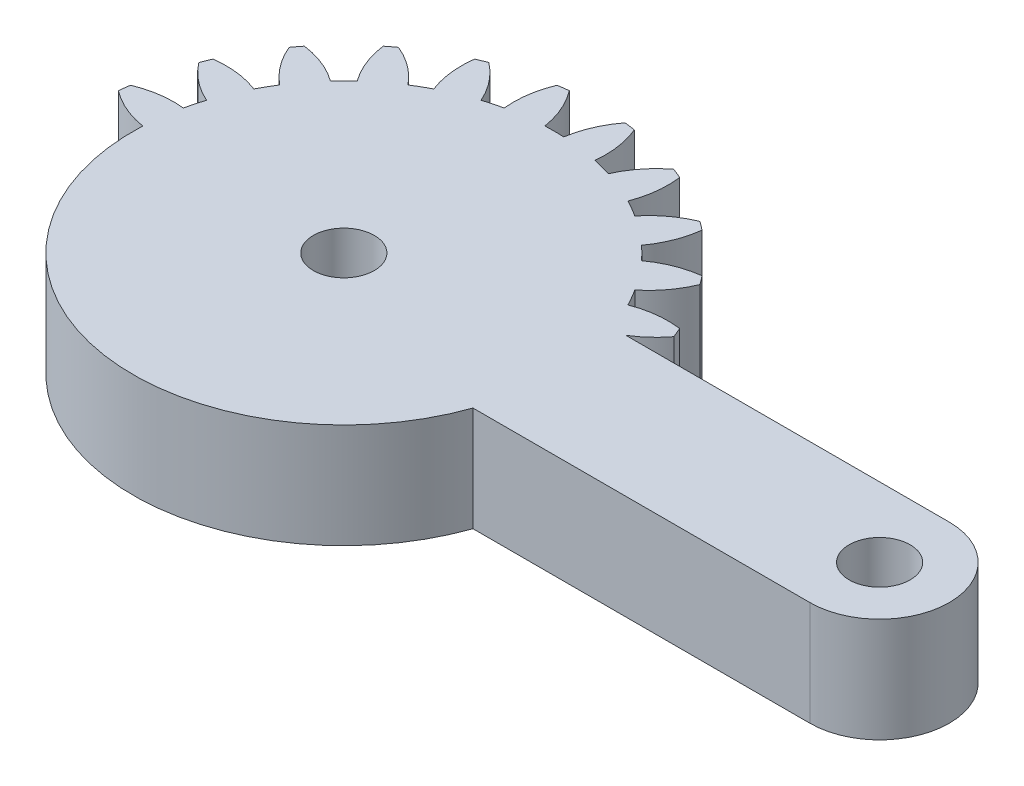
from build123d import *
from build123d.topology import SkipClean

# Parameters (mm, degrees)
SKETCH1_R           = 1.75
BOSS_EXTRUDE1_DEPTH = 4
CUT_EXTRUDE1_DEPTH  = 10
MOVE_FACE1_BY       = 2


with BuildPart() as part:
    # Sketch1 → Boss-Extrude1 (new body)
    with BuildSketch(Plane(origin=(0, 0, 0), x_dir=(1, 0, 0), z_dir=(0, 1, 0))):
        with BuildLine():
            Line((20.643657446, 4), (2.081641936, 4))
            ThreePointArc((2.081641936, 4), (2.861028333, 4.588201733), (3.521749436, 5.30713988))
            ThreePointArc((3.521749436, 5.30713988), (3.405395609, 5.596745198), (3.282888305, 5.883801663))
            ThreePointArc((3.282888305, 5.883801663), (1.93527598, 5.894040025), (0.627094961, 5.57027124))
            ThreePointArc((0.627094961, 5.57027124), (0.366286148, 6.046375), (0.084372603, 6.510293938))
            ThreePointArc((0.084372603, 6.510293938), (1.018855105, 7.48132754), (1.683794586, 8.65351323))
            ThreePointArc((1.683794586, 8.65351323), (1.496450048, 8.903135899), (1.303821399, 9.148703928))
            ThreePointArc((1.303821399, 9.148703928), (-0.000522033, 8.809805691), (-1.180330337, 8.158486898))
            ThreePointArc((-1.180330337, 8.158486898), (-1.555477026, 8.550865528), (-1.947855656, 8.926012217))
            ThreePointArc((-1.947855656, 8.926012217), (-1.296536862, 10.105820521), (-0.957638625, 11.410163953))
            ThreePointArc((-0.957638625, 11.410163953), (-1.203206655, 11.602792602), (-1.452829324, 11.79013714))
            ThreePointArc((-1.452829324, 11.79013714), (-2.625015014, 11.125197659), (-3.596048616, 10.190715157))
            ThreePointArc((-3.596048616, 10.190715157), (-4.059967554, 10.472628702), (-4.536071314, 10.733437515))
            ThreePointArc((-4.536071314, 10.733437515), (-4.212302529, 12.041618533), (-4.222540891, 13.389230859))
            ThreePointArc((-4.222540891, 13.389230859), (-4.509597355, 13.511738163), (-4.799202674, 13.62809199))
            ThreePointArc((-4.799202674, 13.62809199), (-5.759348103, 12.682425791), (-6.455432668, 11.528463019))
            ThreePointArc((-6.455432668, 11.528463019), (-6.976508546, 11.680699536), (-7.503891752, 11.809396783))
            ThreePointArc((-7.503891752, 11.809396783), (-7.529737283, 13.156800143), (-7.888414517, 14.455843809))
            ThreePointArc((-7.888414517, 14.455843809), (-8.197396993, 14.499881098), (-8.507248835, 14.537314892))
            ThreePointArc((-8.507248835, 14.537314892), (-9.18992168, 13.375367565), (-9.563620196, 12.080565177))
            ThreePointArc((-9.563620196, 12.080565177), (-10.106342554, 12.09275), (-10.649064912, 12.080565177))
            ThreePointArc((-10.649064912, 12.080565177), (-11.022763428, 13.375367565), (-11.705436272, 14.537314892))
            ThreePointArc((-11.705436272, 14.537314892), (-12.015288115, 14.499881098), (-12.324270591, 14.455843809))
            ThreePointArc((-12.324270591, 14.455843809), (-12.682947825, 13.156800143), (-12.708793355, 11.809396783))
            ThreePointArc((-12.708793355, 11.809396783), (-13.236176561, 11.680699536), (-13.757252439, 11.528463019))
            ThreePointArc((-13.757252439, 11.528463019), (-14.453337005, 12.682425791), (-15.413482434, 13.62809199))
            ThreePointArc((-15.413482434, 13.62809199), (-15.703087752, 13.511738163), (-15.990144217, 13.389230859))
            ThreePointArc((-15.990144217, 13.389230859), (-16.000382579, 12.041618533), (-15.676613793, 10.733437515))
            ThreePointArc((-15.676613793, 10.733437515), (-16.152717554, 10.472628702), (-16.616636492, 10.190715157))
            ThreePointArc((-16.616636492, 10.190715157), (-17.587670094, 11.125197659), (-18.759855783, 11.79013714))
            ThreePointArc((-18.759855783, 11.79013714), (-19.009478453, 11.602792602), (-19.255046482, 11.410163953))
            ThreePointArc((-19.255046482, 11.410163953), (-18.916148245, 10.105820521), (-18.264829452, 8.926012217))
            ThreePointArc((-18.264829452, 8.926012217), (-18.657208082, 8.550865528), (-19.032354771, 8.158486898))
            ThreePointArc((-19.032354771, 8.158486898), (-20.212163074, 8.809805691), (-21.516506507, 9.148703928))
            ThreePointArc((-21.516506507, 9.148703928), (-21.709135156, 8.903135899), (-21.896479694, 8.65351323))
            ThreePointArc((-21.896479694, 8.65351323), (-21.231540213, 7.48132754), (-20.297057711, 6.510293938))
            ThreePointArc((-20.297057711, 6.510293938), (-20.578971255, 6.046375), (-20.839780068, 5.57027124))
            ThreePointArc((-20.839780068, 5.57027124), (-22.147961087, 5.894040025), (-23.495573413, 5.883801663))
            ThreePointArc((-23.495573413, 5.883801663), (-23.618080717, 5.596745198), (-23.734434544, 5.30713988))
            ThreePointArc((-23.734434544, 5.30713988), (-22.788768345, 4.346994451), (-21.634805572, 3.650909885))
            ThreePointArc((-21.634805572, 3.650909885), (-21.78704209, 3.129834008), (-21.915739337, 2.602450802))
            ThreePointArc((-21.915739337, 2.602450802), (-23.263142697, 2.576605271), (-24.562186363, 2.217928037))
            ThreePointArc((-24.562186363, 2.217928037), (-24.606223651, 1.908945561), (-24.643657446, 1.599093719))
            ThreePointArc((-24.643657446, 1.599093719), (-23.481710119, 0.916420874), (-22.186907731, 0.542722358))
            ThreePointArc((-22.186907731, 0.542722358), (-22.199092554, 0), (-22.186907731, -0.542722358))
            ThreePointArc((-22.186907731, -0.542722358), (-23.481710119, -0.916420874), (-24.643657446, -1.599093719))
            ThreePointArc((-24.643657446, -1.599093719), (-24.606223651, -1.908945561), (-24.562186363, -2.217928037))
            ThreePointArc((-24.562186363, -2.217928037), (-23.263142697, -2.576605271), (-21.915739337, -2.602450802))
            ThreePointArc((-21.915739337, -2.602450802), (-21.78704209, -3.129834008), (-21.634805572, -3.650909885))
            ThreePointArc((-21.634805572, -3.650909885), (-22.788768345, -4.346994451), (-23.734434544, -5.30713988))
            ThreePointArc((-23.734434544, -5.30713988), (-23.618080717, -5.596745198), (-23.495573413, -5.883801663))
            ThreePointArc((-23.495573413, -5.883801663), (-22.147961087, -5.894040025), (-20.839780068, -5.57027124))
            ThreePointArc((-20.839780068, -5.57027124), (-20.578971255, -6.046375), (-20.297057711, -6.510293938))
            ThreePointArc((-20.297057711, -6.510293938), (-21.231540213, -7.48132754), (-21.896479694, -8.65351323))
            ThreePointArc((-21.896479694, -8.65351323), (-21.709135156, -8.903135899), (-21.516506507, -9.148703928))
            ThreePointArc((-21.516506507, -9.148703928), (-20.212163074, -8.809805691), (-19.032354771, -8.158486898))
            ThreePointArc((-19.032354771, -8.158486898), (-18.657208082, -8.550865528), (-18.264829452, -8.926012217))
            ThreePointArc((-18.264829452, -8.926012217), (-18.916148245, -10.105820521), (-19.255046482, -11.410163953))
            ThreePointArc((-19.255046482, -11.410163953), (-19.009478453, -11.602792602), (-18.759855783, -11.79013714))
            ThreePointArc((-18.759855783, -11.79013714), (-17.587670094, -11.125197659), (-16.616636492, -10.190715157))
            ThreePointArc((-16.616636492, -10.190715157), (-16.152717554, -10.472628702), (-15.676613793, -10.733437515))
            ThreePointArc((-15.676613793, -10.733437515), (-16.000382579, -12.041618533), (-15.990144217, -13.389230859))
            ThreePointArc((-15.990144217, -13.389230859), (-15.703087752, -13.511738163), (-15.413482434, -13.62809199))
            ThreePointArc((-15.413482434, -13.62809199), (-14.453337005, -12.682425791), (-13.757252439, -11.528463019))
            ThreePointArc((-13.757252439, -11.528463019), (-13.236176561, -11.680699536), (-12.708793355, -11.809396783))
            ThreePointArc((-12.708793355, -11.809396783), (-12.682947825, -13.156800143), (-12.324270591, -14.455843809))
            ThreePointArc((-12.324270591, -14.455843809), (-12.015288115, -14.499881098), (-11.705436272, -14.537314892))
            ThreePointArc((-11.705436272, -14.537314892), (-11.022763428, -13.375367565), (-10.649064912, -12.080565177))
            ThreePointArc((-10.649064912, -12.080565177), (-10.106342554, -12.09275), (-9.563620196, -12.080565177))
            ThreePointArc((-9.563620196, -12.080565177), (-9.18992168, -13.375367565), (-8.507248835, -14.537314892))
            ThreePointArc((-8.507248835, -14.537314892), (-8.197396993, -14.499881098), (-7.888414517, -14.455843809))
            ThreePointArc((-7.888414517, -14.455843809), (-7.529737283, -13.156800143), (-7.503891752, -11.809396783))
            ThreePointArc((-7.503891752, -11.809396783), (-6.976508546, -11.680699536), (-6.455432668, -11.528463019))
            ThreePointArc((-6.455432668, -11.528463019), (-5.759348103, -12.682425791), (-4.799202674, -13.62809199))
            ThreePointArc((-4.799202674, -13.62809199), (-4.509597355, -13.511738163), (-4.222540891, -13.389230859))
            ThreePointArc((-4.222540891, -13.389230859), (-4.212302529, -12.041618533), (-4.536071314, -10.733437515))
            ThreePointArc((-4.536071314, -10.733437515), (-4.059967554, -10.472628702), (-3.596048616, -10.190715157))
            ThreePointArc((-3.596048616, -10.190715157), (-2.625015014, -11.125197659), (-1.452829324, -11.79013714))
            ThreePointArc((-1.452829324, -11.79013714), (-1.203206655, -11.602792602), (-0.957638625, -11.410163953))
            ThreePointArc((-0.957638625, -11.410163953), (-1.296536862, -10.105820521), (-1.947855656, -8.926012217))
            ThreePointArc((-1.947855656, -8.926012217), (-1.555477026, -8.550865528), (-1.180330337, -8.158486898))
            ThreePointArc((-1.180330337, -8.158486898), (-0.000522033, -8.809805691), (1.303821399, -9.148703928))
            ThreePointArc((1.303821399, -9.148703928), (1.496450048, -8.903135899), (1.683794586, -8.65351323))
            ThreePointArc((1.683794586, -8.65351323), (1.018855105, -7.48132754), (0.084372603, -6.510293938))
            ThreePointArc((0.084372603, -6.510293938), (0.366286148, -6.046375), (0.627094961, -5.57027124))
            ThreePointArc((0.627094961, -5.57027124), (1.93527598, -5.894040025), (3.282888305, -5.883801663))
            ThreePointArc((3.282888305, -5.883801663), (3.405395609, -5.596745198), (3.521749436, -5.30713988))
            ThreePointArc((3.521749436, -5.30713988), (2.861028333, -4.588201733), (2.081641936, -4))
            Line((2.081641936, -4), (20.643657446, -4))
            ThreePointArc((20.643657446, -4), (24.643657446, 0), (20.643657446, 4))
        make_face()
        with Locations(Location((-10.106342554, 0, 0), (0, 0, 270))):
            Circle(SKETCH1_R, mode=Mode.SUBTRACT)
        with Locations(Location((20.643657446, 0, 0), (0, 0, 270))):
            Circle(SKETCH1_R, mode=Mode.SUBTRACT)
    extrude(amount=BOSS_EXTRUDE1_DEPTH)

    # Sketch2 → Cut-Extrude1 (cut)
    with SkipClean():  # the faces are left unmerged after this step: merging them gives an invalid solid
        with BuildSketch(Plane(origin=(0, 4, 0), x_dir=(1, 0, 0), z_dir=(0, 1, 0))):
            with BuildLine():
                ThreePointArc((-24.562186363, -2.217928037), (-23.263142697, -2.576605271), (-21.915739337, -2.602450802))
                ThreePointArc((-21.915739337, -2.602450802), (-22.095637401, -1.578420611), (-22.186907731, -0.542722358))
                ThreePointArc((-22.186907731, -0.542722358), (-23.481710119, -0.916420874), (-24.643657446, -1.599093719))
                ThreePointArc((-24.643657446, -1.599093719), (-24.606223651, -1.908945561), (-24.562186363, -2.217928037))
            make_face()
            with BuildLine():
                ThreePointArc((-23.495573413, -5.883801663), (-22.147961087, -5.894040025), (-20.839780068, -5.57027124))
                ThreePointArc((-20.839780068, -5.57027124), (-21.278586771, -4.627695077), (-21.634805572, -3.650909885))
                ThreePointArc((-21.634805572, -3.650909885), (-22.788768345, -4.346994451), (-23.734434544, -5.30713988))
                ThreePointArc((-23.734434544, -5.30713988), (-23.618080717, -5.596745198), (-23.495573413, -5.883801663))
            make_face()
            with BuildLine():
                ThreePointArc((-21.516506507, -9.148703928), (-20.212163074, -8.809805691), (-19.032354771, -8.158486898))
                ThreePointArc((-19.032354771, -8.158486898), (-19.70016616, -7.361599771), (-20.297057711, -6.510293938))
                ThreePointArc((-20.297057711, -6.510293938), (-21.231540213, -7.48132754), (-21.896479694, -8.65351323))
                ThreePointArc((-21.896479694, -8.65351323), (-21.709135156, -8.903135899), (-21.516506507, -9.148703928))
            make_face()
            with BuildLine():
                ThreePointArc((-18.759855783, -11.79013714), (-17.587670094, -11.125197659), (-16.616636492, -10.190715157))
                ThreePointArc((-16.616636492, -10.190715157), (-17.467942324, -9.593823606), (-18.264829452, -8.926012217))
                ThreePointArc((-18.264829452, -8.926012217), (-18.916148245, -10.105820521), (-19.255046482, -11.410163953))
                ThreePointArc((-19.255046482, -11.410163953), (-19.009478453, -11.602792602), (-18.759855783, -11.79013714))
            make_face()
            with BuildLine():
                ThreePointArc((-15.413482434, -13.62809199), (-14.453337005, -12.682425791), (-13.757252439, -11.528463019))
                ThreePointArc((-13.757252439, -11.528463019), (-14.734037631, -11.172244217), (-15.676613793, -10.733437515))
                ThreePointArc((-15.676613793, -10.733437515), (-16.000382579, -12.041618533), (-15.990144217, -13.389230859))
                ThreePointArc((-15.990144217, -13.389230859), (-15.703087752, -13.511738163), (-15.413482434, -13.62809199))
            make_face()
            with BuildLine():
                ThreePointArc((-11.705436272, -14.537314892), (-11.022763428, -13.375367565), (-10.649064912, -12.080565177))
                ThreePointArc((-10.649064912, -12.080565177), (-11.684763165, -11.989294847), (-12.708793355, -11.809396783))
                ThreePointArc((-12.708793355, -11.809396783), (-12.682947825, -13.156800143), (-12.324270591, -14.455843809))
                ThreePointArc((-12.324270591, -14.455843809), (-12.015288115, -14.499881098), (-11.705436272, -14.537314892))
            make_face()
            with BuildLine():
                ThreePointArc((-7.888414517, -14.455843809), (-7.529737283, -13.156800143), (-7.503891752, -11.809396783))
                ThreePointArc((-7.503891752, -11.809396783), (-8.527921943, -11.989294847), (-9.563620196, -12.080565177))
                ThreePointArc((-9.563620196, -12.080565177), (-9.18992168, -13.375367565), (-8.507248835, -14.537314892))
                ThreePointArc((-8.507248835, -14.537314892), (-8.197396993, -14.499881098), (-7.888414517, -14.455843809))
            make_face()
            with BuildLine():
                ThreePointArc((-4.222540891, -13.389230859), (-4.212302529, -12.041618533), (-4.536071314, -10.733437515))
                ThreePointArc((-4.536071314, -10.733437515), (-5.478647477, -11.172244217), (-6.455432668, -11.528463019))
                ThreePointArc((-6.455432668, -11.528463019), (-5.759348103, -12.682425791), (-4.799202674, -13.62809199))
                ThreePointArc((-4.799202674, -13.62809199), (-4.509597355, -13.511738163), (-4.222540891, -13.389230859))
            make_face()
            with BuildLine():
                ThreePointArc((-0.957638625, -11.410163953), (-1.296536862, -10.105820521), (-1.947855656, -8.926012217))
                ThreePointArc((-1.947855656, -8.926012217), (-2.744742783, -9.593823606), (-3.596048616, -10.190715157))
                ThreePointArc((-3.596048616, -10.190715157), (-2.625015014, -11.125197659), (-1.452829324, -11.79013714))
                ThreePointArc((-1.452829324, -11.79013714), (-1.203206655, -11.602792602), (-0.957638625, -11.410163953))
            make_face()
            with BuildLine():
                ThreePointArc((1.683794586, -8.65351323), (1.018855105, -7.48132754), (0.084372603, -6.510293938))
                ThreePointArc((0.084372603, -6.510293938), (-0.512518948, -7.361599771), (-1.180330337, -8.158486898))
                ThreePointArc((-1.180330337, -8.158486898), (-0.000522033, -8.809805691), (1.303821399, -9.148703928))
                ThreePointArc((1.303821399, -9.148703928), (1.496450048, -8.903135899), (1.683794586, -8.65351323))
            make_face()
            with BuildLine():
                ThreePointArc((3.521749436, -5.30713988), (2.861028333, -4.588201733), (2.081641936, -4))
                Line((2.081641936, -4), (1.305695063, -4))
                ThreePointArc((1.305695063, -4), (0.994195953, -4.797149927), (0.627094961, -5.57027124))
                ThreePointArc((0.627094961, -5.57027124), (1.93527598, -5.894040025), (3.282888305, -5.883801663))
                ThreePointArc((3.282888305, -5.883801663), (3.405395609, -5.596745198), (3.521749436, -5.30713988))
            make_face()
        extrude(amount=-CUT_EXTRUDE1_DEPTH, mode=Mode.SUBTRACT)

    # Move Face1: a face moved outward by 2.0
    extrude(part.faces().sort_by_distance((-4.527591371, 0, -0.601969307))[0], amount=MOVE_FACE1_BY, dir=(0, -1, 0))


solid = part.part
